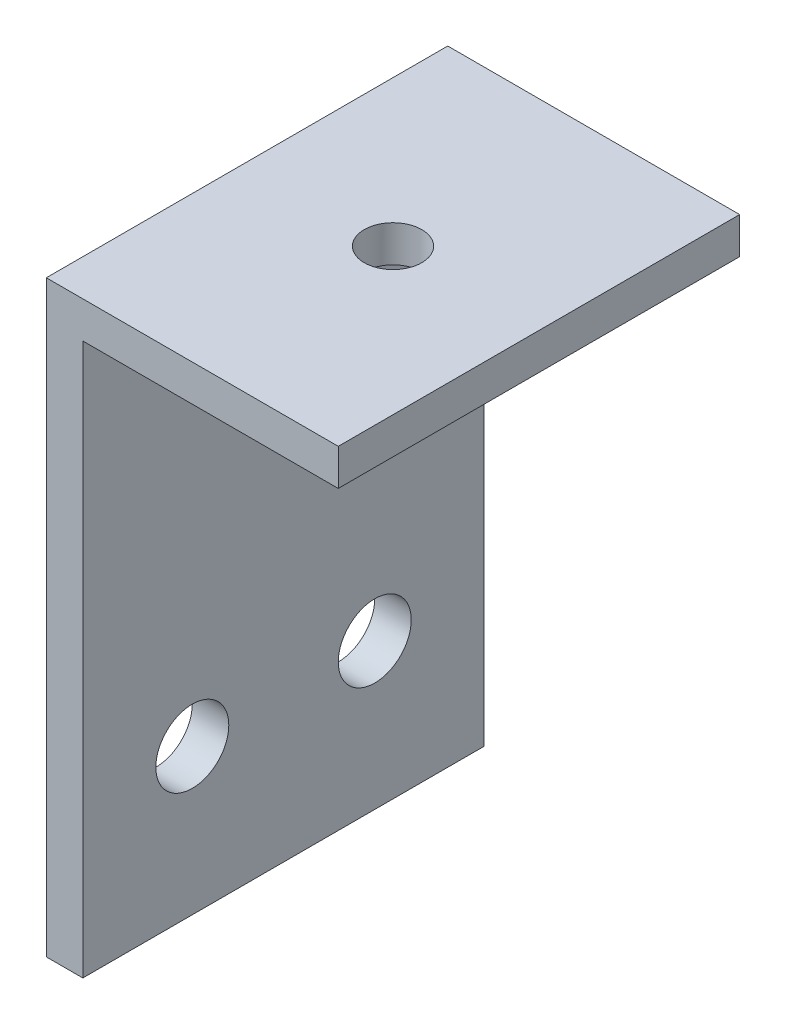
from build123d import *

# Parameters (mm, degrees)
BOSS_EXTRUDE1_DEPTH = 34.925
SKETCH2_R           = 3.175
CUT_EXTRUDE1_DEPTH  = 4.175
SKETCH3_R           = 2.5
CUT_EXTRUDE2_DEPTH  = 52.175


with BuildPart() as part:
    # Sketch1 → Boss-Extrude1 (new body)
    with BuildSketch(Plane.XY):
        Polygon((0, 0), (3.175, 0), (3.175, 48), (25.4, 48), (25.4, 51.175), (0, 51.175), align=None)
    extrude(amount=BOSS_EXTRUDE1_DEPTH)

    # Sketch2 → Cut-Extrude1 (cut, through all)
    with BuildSketch(Plane(origin=(3.175, 0, 0), x_dir=(0, 0, -1), z_dir=(1, 0, 0))):
        with Locations((-25.4, 12.7)):
            Circle(SKETCH2_R)
        with Locations((-9.525, 12.7)):
            Circle(SKETCH2_R)
    extrude(amount=-CUT_EXTRUDE1_DEPTH, mode=Mode.SUBTRACT)

    # Sketch3 → Cut-Extrude2 (cut, through all)
    with BuildSketch(Plane(origin=(0, 51.175, 0), x_dir=(1, 0, 0), z_dir=(0, 1, 0))):
        with Locations((12.7, -17.4625)):
            Circle(SKETCH3_R)
    extrude(amount=-CUT_EXTRUDE2_DEPTH, mode=Mode.SUBTRACT)


solid = part.part
